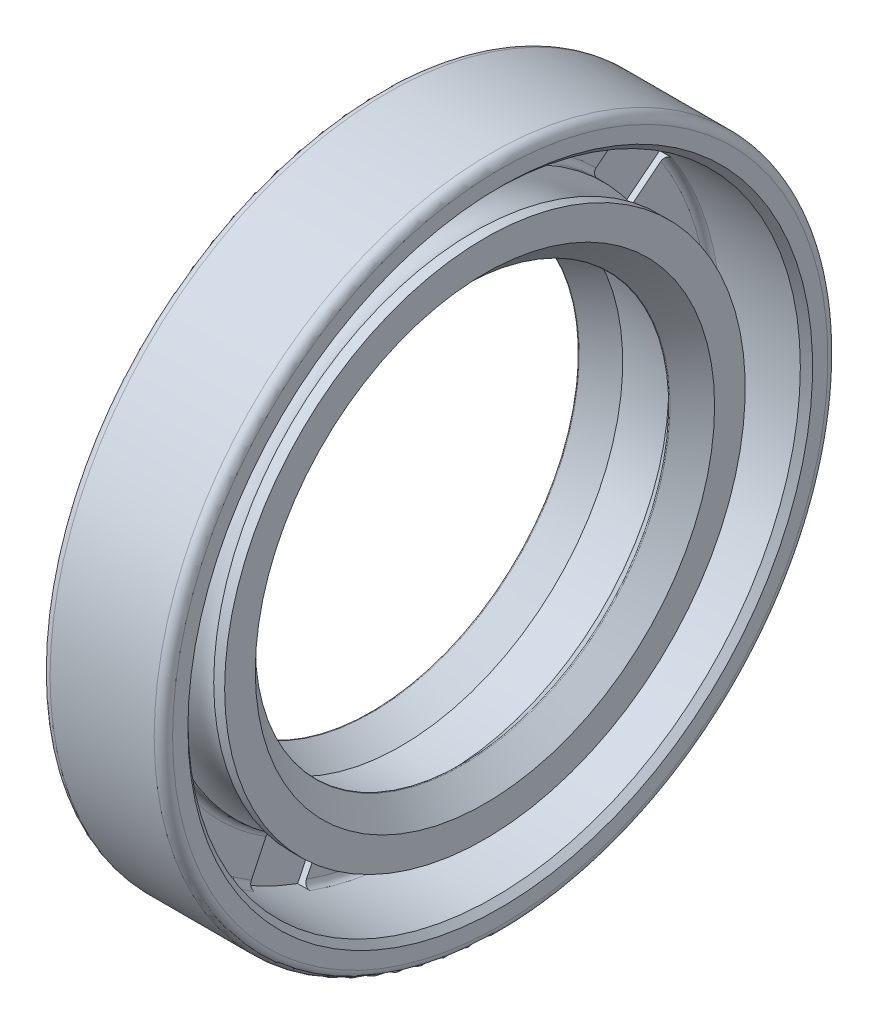
from build123d import *
from build123d.topology import SkipClean

# Parameters (mm, degrees)
CUT_EXTRUDE_1_DEPTH      = 0.1
EXTRUDE_1_DEPTH          = 0.1
CUT_EXTRUDE_2_DEPTH      = 0.3
CUT_EXTRUDE_2_DEPTH_BACK = 0.2


with BuildPart() as part:
    # Эскиз1 → Повернуть1 (revolve)
    with BuildSketch(Plane.XY, mode=Mode.PRIVATE) as revolve_1_sk:
        with BuildLine():
            Line((3.8, 10), (4, 10.2))
            Line((4, 10.2), (4, 10.7))
            ThreePointArc((4, 10.7), (3.912132034, 10.912132034), (3.7, 11))
            Line((3.7, 11), (0.3, 11))
            ThreePointArc((0.3, 11), (0.087867966, 10.912132034), (0, 10.7))
            Line((0, 10.7), (0, 7.5))
            Line((0, 7.5), (0.1, 7.5))
            Line((0.1, 7.5), (0.1, 7.4))
            Line((0.1, 7.4), (-0.226285117, 6.806886442))
            ThreePointArc((-0.226285117, 6.806886442), (-0.221483169, 6.771486649), (-0.186217991, 6.765779527))
            Line((-0.186217991, 6.765779527), (0.75, 7.25))
            Line((0.75, 7.25), (2.25, 7.25))
            Line((2.25, 7.25), (2.728786797, 6.771213203))
            ThreePointArc((2.728786797, 6.771213203), (2.75, 6.762426407), (2.771213203, 6.771213203))
            Line((2.771213203, 6.771213203), (3.5, 7.5))
            Line((3.5, 7.5), (3.5, 8.5))
            Line((3.5, 8.5), (3.143028555, 8.5))
            ThreePointArc((3.143028555, 8.5), (2.25, 7.95), (1.356971445, 8.5))
            Line((1.356971445, 8.5), (1.2, 8.5))
            ThreePointArc((1.2, 8.5), (1.058578644, 8.558578644), (1, 8.7))
            Line((1, 8.7), (1, 9.8))
            ThreePointArc((1, 9.8), (1.058578644, 9.941421356), (1.2, 10))
            Line((1.2, 10), (3.8, 10))
        make_face()
    revolve(revolve_1_sk.sketch.rotate(Axis((0, 0, 0), (1, 0, 0)), 90), axis=Axis((0, 0, 0), (1, 0, 0)))

    # Эскиз2 → Вырез-Вытянуть1 (cut)
    with BuildSketch(Plane.ZY):
        with BuildLine():
            Line((-1, 10.351811436), (-1, 8.851811436))
            ThreePointArc((-1, 8.851811436), (-1.344740951, 7.79988362), (-2.245223812, 7.156044301))
            ThreePointArc((-2.245223812, 7.156044301), (0, 7.5), (2.245223812, 7.156044301))
            ThreePointArc((2.245223812, 7.156044301), (1.344740951, 7.79988362), (1, 8.851811436))
            Line((1, 8.851811436), (1, 10.351811436))
            ThreePointArc((1, 10.351811436), (0, 10.4), (-1, 10.351811436))
        make_face()
        with BuildLine():
            Line((7.469882279, 7.236080343), (6.297135055, 6.300845641))
            ThreePointArc((6.297135055, 6.300845641), (5.259762305, 5.914508704), (4.194946575, 6.217107304))
            ThreePointArc((4.194946575, 6.217107304), (5.863736119, 4.676173514), (6.994694874, 2.706333982))
            ThreePointArc((6.994694874, 2.706333982), (6.936626843, 3.811787082), (7.544114659, 4.737182676))
            Line((7.544114659, 4.737182676), (8.716861883, 5.672417378))
            ThreePointArc((8.716861883, 5.672417378), (8.131047418, 6.484293939), (7.469882279, 7.236080343))
        make_face()
        with BuildLine():
            Line((10.314790844, -1.328566837), (8.852398976, -0.994785436))
            ThreePointArc((8.852398976, -0.994785436), (7.903557265, -0.424611901), (7.476236629, 0.596561702))
            ThreePointArc((7.476236629, 0.596561702), (7.311959341, -1.668907005), (6.47701803, -3.781301024))
            ThreePointArc((6.47701803, -3.781301024), (7.305091241, -3.046662875), (8.407357108, -2.94464126))
            Line((8.407357108, -2.94464126), (9.869748976, -3.278422661))
            ThreePointArc((9.869748976, -3.278422661), (10.139250287, -2.314217713), (10.314790844, -1.328566837))
        make_face()
        with BuildLine():
            Line((5.39245152, -8.892776091), (4.741625912, -7.541322789))
            ThreePointArc((4.741625912, -7.541322789), (4.595812402, -6.443991083), (5.127768014, -5.47320703))
            ThreePointArc((5.127768014, -5.47320703), (3.254128043, -6.757266509), (1.082014503, -7.421539235))
            ThreePointArc((1.082014503, -7.421539235), (2.172672938, -7.610913547), (2.939688176, -8.409090267))
            Line((2.939688176, -8.409090267), (3.590513784, -9.760543569))
            ThreePointArc((3.590513784, -9.760543569), (4.512390887, -9.370076226), (5.39245152, -8.892776091))
        make_face()
        with BuildLine():
            Line((-3.590513784, -9.760543569), (-2.939688176, -8.409090267))
            ThreePointArc((-2.939688176, -8.409090267), (-2.172672938, -7.610913547), (-1.082014503, -7.421539235))
            ThreePointArc((-1.082014503, -7.421539235), (-3.254128043, -6.757266509), (-5.127768014, -5.47320703))
            ThreePointArc((-5.127768014, -5.47320703), (-4.595812402, -6.443991083), (-4.741625912, -7.541322789))
            Line((-4.741625912, -7.541322789), (-5.39245152, -8.892776091))
            ThreePointArc((-5.39245152, -8.892776091), (-4.512390887, -9.370076226), (-3.590513784, -9.760543569))
        make_face()
        with BuildLine():
            Line((-9.869748976, -3.278422661), (-8.407357108, -2.94464126))
            ThreePointArc((-8.407357108, -2.94464126), (-7.305091241, -3.046662875), (-6.47701803, -3.781301024))
            ThreePointArc((-6.47701803, -3.781301024), (-7.311959341, -1.668907005), (-7.476236629, 0.596561702))
            ThreePointArc((-7.476236629, 0.596561702), (-7.903557265, -0.424611901), (-8.852398976, -0.994785436))
            Line((-8.852398976, -0.994785436), (-10.314790844, -1.328566837))
            ThreePointArc((-10.314790844, -1.328566837), (-10.139250287, -2.314217713), (-9.869748976, -3.278422661))
        make_face()
        with BuildLine():
            Line((-8.716861883, 5.672417378), (-7.544114659, 4.737182676))
            ThreePointArc((-7.544114659, 4.737182676), (-6.936626843, 3.811787082), (-6.994694874, 2.706333982))
            ThreePointArc((-6.994694874, 2.706333982), (-5.863736119, 4.676173514), (-4.194946575, 6.217107304))
            ThreePointArc((-4.194946575, 6.217107304), (-5.259762305, 5.914508704), (-6.297135055, 6.300845641))
            Line((-6.297135055, 6.300845641), (-7.469882279, 7.236080343))
            ThreePointArc((-7.469882279, 7.236080343), (-8.131047418, 6.484293939), (-8.716861883, 5.672417378))
        make_face()
    extrude(amount=-CUT_EXTRUDE_1_DEPTH, mode=Mode.SUBTRACT)

    # Эскиз3 → Бобышка-Вытянуть1 (add)
    with BuildSketch(Plane.ZY):
        with BuildLine():
            Line((9.588913533, 1.33928681), (9.468080199, 1.317672227))
            Line((9.468080199, 1.317672227), (9.386569783, 1.76975556))
            Line((9.386569783, 1.76975556), (9.029278116, 1.77053681))
            add(Edge.make_bspline(
                [(9.029278116, 1.77053681), (9.035465049, 1.757775142), (9.04742158, 1.733112633), (9.061601236, 1.695833664), (9.073210139, 1.660384245), (9.078009986, 1.63682296), (9.080319783, 1.625484727)],
                knots=[0, 0, 0, 0, 1.102671341, 2.130962978, 3.100576271, 4, 4, 4, 4], degree=3))
            add(Edge.make_bspline(
                [(9.080319783, 1.625484727), (9.082501781, 1.611277835), (9.086782503, 1.583406247), (9.088462989, 1.541710229), (9.086595342, 1.50120977), (9.080140882, 1.461992911), (9.070367346, 1.423943575), (9.056197187, 1.387243637), (9.037669999, 1.352026263), (9.016054421, 1.318019494), (8.990847303, 1.286399108), (8.962854268, 1.25761246), (8.932291016, 1.231810596), (8.898614543, 1.209773507), (8.86266967, 1.190269117), (8.823778149, 1.174599529), (8.782526714, 1.161196232), (8.753658084, 1.155485034), (8.738913533, 1.15256806)],
                knots=[0, 0, 0, 0, 1.054632134, 2.069014926, 3.058236692, 4.026435499, 4.98181551, 5.938194216, 6.907420423, 7.899266887, 8.892668482, 9.870739776, 10.843480261, 11.822796767, 12.820828869, 13.84110145, 14.897350115, 16, 16, 16, 16], degree=3))
            add(Edge.make_bspline(
                [(8.738913533, 1.15256806), (8.718301703, 1.149499747), (8.677659031, 1.143449608), (8.616404687, 1.144008967), (8.556545655, 1.152050985), (8.508178047, 1.165290204), (8.470735254, 1.178870217), (8.444154528, 1.191425999), (8.418474695, 1.204669458), (8.394558088, 1.220347426), (8.37152675, 1.23690558), (8.349769257, 1.255196589), (8.329609308, 1.275323468), (8.310400181, 1.296613929), (8.293177936, 1.319672847), (8.276698312, 1.343554884), (8.262672315, 1.369251451), (8.249373401, 1.395746425), (8.238373521, 1.423834635), (8.22829654, 1.452936979), (8.220331805, 1.483550735), (8.216074336, 1.504457302), (8.213913533, 1.51506806)],
                knots=[0, 0, 0, 0, 1.746782277, 3.444327802, 5.120713648, 6.803167765, 7.64223887, 8.46046003, 9.268727784, 10.06498721, 10.857739235, 11.648782055, 12.44730472, 13.247155712, 14.052957073, 14.861224827, 15.679964794, 16.5075709, 17.347716724, 18.209383447, 19.091204212, 20, 20, 20, 20], degree=3))
            add(Edge.make_bspline(
                [(8.213913533, 1.51506806), (8.211860736, 1.527713333), (8.207814692, 1.55263705), (8.205793798, 1.589973093), (8.207206721, 1.626283926), (8.211184773, 1.661631073), (8.218837253, 1.695999064), (8.229828493, 1.729367785), (8.24395701, 1.761796776), (8.261138698, 1.792997667), (8.281015382, 1.822460746), (8.30338295, 1.849779748), (8.327776982, 1.874819928), (8.354660779, 1.89733801), (8.383492712, 1.917712939), (8.41476775, 1.935451835), (8.448122544, 1.950923612), (8.471562549, 1.959100239), (8.483444783, 1.963245143)],
                knots=[0, 0, 0, 0, 1.070277629, 2.109507287, 3.118742823, 4.105157841, 5.078705733, 6.056193492, 7.037551653, 8.031278571, 9.029472413, 10.004074294, 10.978973248, 11.947043653, 12.931428349, 13.925923206, 14.948606654, 16, 16, 16, 16], degree=3))
            Line((8.483444783, 1.963245143), (8.506882283, 1.83303681))
            add(Edge.make_bspline(
                [(8.506882283, 1.83303681), (8.495664343, 1.828312816), (8.474049287, 1.819210486), (8.44436308, 1.802356173), (8.418329605, 1.783766395), (8.396397922, 1.762563604), (8.37795042, 1.739236954), (8.362186693, 1.713738496), (8.349096987, 1.685708453), (8.339194806, 1.655511971), (8.332070708, 1.624137755), (8.328625933, 1.592244369), (8.329126299, 1.560235375), (8.332175156, 1.539177467), (8.333705199, 1.528609727)],
                knots=[0, 0, 0, 0, 1.145991483, 2.208130174, 3.209320006, 4.152151774, 5.071818133, 6.004664262, 6.970625265, 7.979303532, 8.993273262, 9.996732158, 10.994676309, 12, 12, 12, 12], degree=3))
            add(Edge.make_bspline(
                [(8.333705199, 1.528609727), (8.335839735, 1.518399078), (8.340037362, 1.498319536), (8.349901331, 1.469362208), (8.362302411, 1.441959603), (8.377789535, 1.416340658), (8.396017482, 1.392409644), (8.416814348, 1.369919107), (8.440755295, 1.349407874), (8.466871381, 1.330418787), (8.494966161, 1.313963304), (8.524309484, 1.30022419), (8.554732046, 1.289874382), (8.586063175, 1.282109357), (8.618491511, 1.278135279), (8.651755457, 1.276877334), (8.686054737, 1.278212844), (8.708992702, 1.281925626), (8.720684366, 1.28381806)],
                knots=[0, 0, 0, 0, 0.981009174, 1.929183594, 2.872417366, 3.806977866, 4.740001525, 5.699616796, 6.684157724, 7.702294877, 8.734980607, 9.743831539, 10.746310718, 11.754930054, 12.776405264, 13.814795504, 14.886183815, 16, 16, 16, 16], degree=3))
            add(Edge.make_bspline(
                [(8.720684366, 1.28381806), (8.731055122, 1.285994385), (8.751398612, 1.290263511), (8.780721187, 1.299415065), (8.808072282, 1.310882369), (8.833568977, 1.324397299), (8.856900782, 1.340471863), (8.878392584, 1.358697855), (8.897661044, 1.379483473), (8.91511876, 1.402073827), (8.930280188, 1.426401237), (8.942244992, 1.452470277), (8.951592086, 1.47961082), (8.958586316, 1.507987621), (8.96206941, 1.537714124), (8.962734891, 1.568556211), (8.961031485, 1.600639017), (8.957602986, 1.622209322), (8.955840616, 1.633297227)],
                knots=[0, 0, 0, 0, 1.071476955, 2.101831487, 3.101497072, 4.067906914, 5.015341607, 5.962043589, 6.91252516, 7.876738478, 8.846612665, 9.8051719, 10.77154185, 11.746965016, 12.755499628, 13.791972177, 14.864995145, 16, 16, 16, 16], degree=3))
            add(Edge.make_bspline(
                [(8.955840616, 1.633297227), (8.953890867, 1.642877789), (8.949885863, 1.66255735), (8.941105073, 1.692271622), (8.930054115, 1.723090319), (8.916893416, 1.755094434), (8.900747926, 1.787965728), (8.882482686, 1.822084346), (8.862054192, 1.857450334), (8.846914154, 1.880929259), (8.839173949, 1.892932643)],
                knots=[0, 0, 0, 0, 0.818829657, 1.681968923, 2.59290151, 3.561306049, 4.579422007, 5.659649051, 6.803517188, 8, 8, 8, 8], degree=3))
            Line((8.839173949, 1.892932643), (9.489955199, 1.888765977))
            Line((9.489955199, 1.888765977), (9.588913533, 1.33928681))
        make_face()
        Polygon((4.381995522, 8.674018158), (4.405693438, 8.663080658), (4.021318438, 7.845632741), (4.163505938, 7.778705658), (4.110641355, 7.666205658), (3.968453855, 7.733132741), (3.840068438, 7.460476491), (3.722880938, 7.515424408), (3.851266355, 7.788080658), (3.290589272, 8.051882741), align=None)
        Polygon((3.904130938, 7.900580658), (4.134078855, 8.389643158), (3.558818438, 8.063080658), align=None, mode=Mode.SUBTRACT)
        with BuildLine():
            Line((-3.829708602, 8.452844517), (-3.944552352, 8.405188267))
            add(Edge.make_bspline(
                [(-3.944552352, 8.405188267), (-3.949859452, 8.41994751), (-3.960313259, 8.449019941), (-3.971057457, 8.493358081), (-3.978110879, 8.536983544), (-3.980294709, 8.580085731), (-3.978938574, 8.622571089), (-3.972892066, 8.664576179), (-3.962237646, 8.705817947), (-3.948162825, 8.746304697), (-3.929896663, 8.784799666), (-3.908766046, 8.821120294), (-3.884292716, 8.854521186), (-3.856455161, 8.884809492), (-3.825811178, 8.912480959), (-3.791738267, 8.936895149), (-3.754655806, 8.958758112), (-3.728101027, 8.970549437), (-3.714604436, 8.976542433)],
                knots=[0, 0, 0, 0, 1.096521486, 2.159903834, 3.186245968, 4.183651723, 5.17415673, 6.155760999, 7.145502496, 8.149981878, 9.149677297, 10.121389001, 11.085767646, 12.039997892, 12.994653141, 13.968847404, 14.967657124, 16, 16, 16, 16], degree=3))
            add(Edge.make_bspline(
                [(-3.714604436, 8.976542433), (-3.700967671, 8.981800704), (-3.674298183, 8.992084331), (-3.633728967, 9.003442013), (-3.5936637, 9.010232709), (-3.55421364, 9.012941536), (-3.515385206, 9.011273051), (-3.477090376, 9.005937321), (-3.439394044, 8.995875642), (-3.402733974, 8.9817443), (-3.367543252, 8.964798788), (-3.33477103, 8.944880717), (-3.304782781, 8.922461629), (-3.277332771, 8.897555308), (-3.253032619, 8.869819767), (-3.230792357, 8.839993144), (-3.211790224, 8.807307801), (-3.201379274, 8.784107352), (-3.196114852, 8.772375767)],
                knots=[0, 0, 0, 0, 1.126668478, 2.203431106, 3.242301841, 4.255315755, 5.246847215, 6.23423487, 7.231174724, 8.248139917, 9.260069506, 10.239345753, 11.200610572, 12.143519972, 13.091902427, 14.039812275, 15.008807544, 16, 16, 16, 16], degree=3))
            add(Edge.make_bspline(
                [(-3.196114852, 8.772375767), (-3.18963113, 8.755424988), (-3.176769082, 8.721798977), (-3.166249159, 8.668819192), (-3.161492723, 8.615155709), (-3.163984029, 8.569420349), (-3.169204722, 8.531104079), (-3.175335459, 8.498976953), (-3.183384434, 8.463704251), (-3.193702689, 8.425272747), (-3.205898583, 8.383665582), (-3.220426765, 8.338872854), (-3.236311812, 8.290711742), (-3.248442574, 8.257843253), (-3.254708602, 8.24086535)],
                knots=[0, 0, 0, 0, 1.188437879, 2.357556985, 3.528739948, 4.714365017, 5.352092814, 6.064537005, 6.858720112, 7.724625659, 8.674082858, 9.70222094, 10.813104245, 12, 12, 12, 12], degree=3))
            Line((-3.254708602, 8.24086535), (-3.418510686, 7.79555285))
            Line((-3.418510686, 7.79555285), (-2.865906519, 8.025500767))
            Line((-2.865906519, 8.025500767), (-2.817729436, 7.909875767))
            Line((-2.817729436, 7.909875767), (-3.630750269, 7.571594517))
            Line((-3.630750269, 7.571594517), (-3.379187769, 8.255969517))
            add(Edge.make_bspline(
                [(-3.379187769, 8.255969517), (-3.373044883, 8.272525513), (-3.361210096, 8.304422034), (-3.345245929, 8.350701861), (-3.330789427, 8.393165163), (-3.318421622, 8.43191544), (-3.308581228, 8.467153469), (-3.30049242, 8.49866531), (-3.29398151, 8.52646694), (-3.28882884, 8.5585649), (-3.28607861, 8.595878122), (-3.288390751, 8.639198683), (-3.296247868, 8.681394616), (-3.306220137, 8.707998268), (-3.311219019, 8.7213341)],
                knots=[0, 0, 0, 0, 1.31832802, 2.539869931, 3.654741466, 4.667269092, 5.576164967, 6.385658026, 7.09632402, 7.706819853, 8.811282941, 9.882190626, 10.938388291, 12, 12, 12, 12], degree=3))
            add(Edge.make_bspline(
                [(-3.311219019, 8.7213341), (-3.314881885, 8.729484973), (-3.322153229, 8.745665696), (-3.335706648, 8.768336319), (-3.351486167, 8.788986849), (-3.369019018, 8.807921236), (-3.388570976, 8.82488006), (-3.410248629, 8.839770105), (-3.433655224, 8.853201424), (-3.459022006, 8.864049005), (-3.485112496, 8.873327484), (-3.511833881, 8.87963576), (-3.538645531, 8.882846255), (-3.565573225, 8.884082899), (-3.592563893, 8.882241098), (-3.619637857, 8.877371906), (-3.646862316, 8.870143325), (-3.664659656, 8.863339242), (-3.673719019, 8.859875767)],
                knots=[0, 0, 0, 0, 0.993378952, 1.972008145, 2.929839696, 3.879460273, 4.837729712, 5.801963692, 6.800770985, 7.834077465, 8.866165237, 9.877909366, 10.880303721, 11.865909819, 12.872341706, 13.881918122, 14.921834737, 16, 16, 16, 16], degree=3))
            add(Edge.make_bspline(
                [(-3.673719019, 8.859875767), (-3.6830189, 8.855818349), (-3.701278625, 8.847851866), (-3.726584708, 8.832725104), (-3.749907143, 8.816161223), (-3.770922481, 8.797378237), (-3.789999254, 8.776977196), (-3.806446354, 8.754276853), (-3.820818782, 8.729947355), (-3.833107099, 8.703938749), (-3.842713877, 8.676359875), (-3.849507899, 8.647559687), (-3.853394247, 8.617721228), (-3.854418722, 8.586764066), (-3.852433838, 8.5547253), (-3.848090445, 8.5215136), (-3.84045012, 8.487310313), (-3.833346201, 8.464516308), (-3.829708602, 8.452844517)],
                knots=[0, 0, 0, 0, 1.002791797, 1.968918082, 2.910264302, 3.828773152, 4.752445691, 5.667898733, 6.595713322, 7.544549858, 8.5086514, 9.479270434, 10.466648568, 11.480519657, 12.538453784, 13.638754709, 14.79091189, 16, 16, 16, 16], degree=3))
        make_face()
        with BuildLine():
            Line((-4.803383084, 7.936228802), (-4.911195584, 7.875551719))
            add(Edge.make_bspline(
                [(-4.911195584, 7.875551719), (-4.918117154, 7.889507673), (-4.931768312, 7.917032487), (-4.947788447, 7.95939507), (-4.959841908, 8.001703843), (-4.966934077, 8.04398293), (-4.970589336, 8.086246753), (-4.969434347, 8.128402835), (-4.964154857, 8.17051965), (-4.954817842, 8.212108652), (-4.941740388, 8.252566881), (-4.924578976, 8.290709227), (-4.904563186, 8.326736529), (-4.88072613, 8.36010327), (-4.853530249, 8.391129345), (-4.822513208, 8.419125361), (-4.788557738, 8.445330195), (-4.763704764, 8.4601744), (-4.751039334, 8.467739219)],
                knots=[0, 0, 0, 0, 1.093816138, 2.157293325, 3.176725589, 4.179274344, 5.164272884, 6.152475292, 7.13577344, 8.141821374, 9.142680977, 10.117260979, 11.075622659, 12.033343872, 12.992520074, 13.967996364, 14.964461964, 16, 16, 16, 16], degree=3))
            add(Edge.make_bspline(
                [(-4.751039334, 8.467739219), (-4.738223847, 8.474583159), (-4.713101342, 8.487999497), (-4.674138623, 8.503549845), (-4.635379641, 8.515182713), (-4.596641067, 8.522664782), (-4.557943364, 8.525348534), (-4.519336861, 8.524528221), (-4.480967872, 8.518816152), (-4.443017213, 8.509525257), (-4.406444543, 8.496459694), (-4.371603657, 8.481000913), (-4.339344462, 8.462244295), (-4.309265186, 8.440994952), (-4.281786745, 8.416444525), (-4.256420367, 8.38938955), (-4.233645949, 8.359292917), (-4.220635448, 8.337571175), (-4.214060168, 8.326593385)],
                knots=[0, 0, 0, 0, 1.123995911, 2.20339595, 3.240965662, 4.253156185, 5.250447687, 6.2386417, 7.236499041, 8.24699283, 9.25864785, 10.239134739, 11.193505465, 12.142633332, 13.085196562, 14.040867601, 15.009888581, 16, 16, 16, 16], degree=3))
            add(Edge.make_bspline(
                [(-4.214060168, 8.326593385), (-4.205738272, 8.310550627), (-4.189254274, 8.27877316), (-4.172018278, 8.227839312), (-4.161637067, 8.175218396), (-4.158353148, 8.129678553), (-4.159185652, 8.091145511), (-4.161371643, 8.058660686), (-4.164977605, 8.022858865), (-4.170569518, 7.983615085), (-4.177937647, 7.94100852), (-4.186799568, 7.894994973), (-4.197216766, 7.845573592), (-4.205219831, 7.811646345), (-4.209372668, 7.794041302)],
                knots=[0, 0, 0, 0, 1.188925002, 2.355020631, 3.526652616, 4.713156068, 5.353552139, 6.063922859, 6.85690597, 7.722805645, 8.673945646, 9.704338504, 10.80876811, 12, 12, 12, 12], degree=3))
            Line((-4.209372668, 7.794041302), (-4.319008084, 7.334145469))
            Line((-4.319008084, 7.334145469), (-3.799476834, 7.627114219))
            Line((-3.799476834, 7.627114219), (-3.738278918, 7.518520469))
            Line((-3.738278918, 7.518520469), (-4.502601834, 7.087791302))
            Line((-4.502601834, 7.087791302), (-4.334372668, 7.794301719))
            add(Edge.make_bspline(
                [(-4.334372668, 7.794301719), (-4.330215646, 7.811471535), (-4.322232146, 7.844445925), (-4.311971793, 7.892180698), (-4.302747737, 7.935892728), (-4.295096839, 7.975712801), (-4.289308904, 8.011761235), (-4.285254523, 8.043913134), (-4.282079136, 8.072191101), (-4.280716524, 8.104460545), (-4.28240452, 8.141638725), (-4.289614933, 8.184235249), (-4.302580351, 8.224969602), (-4.315442542, 8.250185337), (-4.321872668, 8.262791302)],
                knots=[0, 0, 0, 0, 1.323703953, 2.542154804, 3.658395355, 4.671322923, 5.580296802, 6.393557515, 7.099691824, 7.711680269, 8.812193497, 9.881567138, 10.940943348, 12, 12, 12, 12], degree=3))
            add(Edge.make_bspline(
                [(-4.321872668, 8.262791302), (-4.326522974, 8.270422686), (-4.335718589, 8.285513146), (-4.351549452, 8.30656144), (-4.369701747, 8.324917234), (-4.389174168, 8.341658667), (-4.410456775, 8.356210479), (-4.433697038, 8.36844416), (-4.458440493, 8.37901633), (-4.484783544, 8.386821935), (-4.511763803, 8.392642911), (-4.538885724, 8.395735913), (-4.565847534, 8.396386855), (-4.592531439, 8.393908443), (-4.619011912, 8.389050423), (-4.645176218, 8.380999487), (-4.671308644, 8.370705063), (-4.688095639, 8.361826797), (-4.696612251, 8.357322552)],
                knots=[0, 0, 0, 0, 0.997680993, 1.972835486, 2.932499176, 3.874524755, 4.837023499, 5.804050757, 6.803190383, 7.83653798, 8.866926321, 9.881694852, 10.880270099, 11.87280533, 12.868978396, 13.880965465, 14.924941931, 16, 16, 16, 16], degree=3))
            add(Edge.make_bspline(
                [(-4.696612251, 8.357322552), (-4.705291946, 8.352074401), (-4.722308708, 8.341785267), (-4.74596039, 8.32432308), (-4.766876384, 8.304903835), (-4.78543912, 8.283899887), (-4.80206103, 8.261513291), (-4.815802603, 8.237224609), (-4.827041084, 8.21133647), (-4.83622046, 8.184213364), (-4.842399694, 8.155738954), (-4.845884304, 8.126433239), (-4.846021176, 8.09641285), (-4.843355028, 8.06565491), (-4.837852631, 8.034207246), (-4.829447443, 8.001972183), (-4.81792739, 7.969096019), (-4.808310524, 7.947363829), (-4.803383084, 7.936228802)],
                knots=[0, 0, 0, 0, 1.006622235, 1.973508445, 2.912614938, 3.834361958, 4.753042397, 5.675473967, 6.597704251, 7.551483334, 8.513287118, 9.48492351, 10.475969956, 11.487889852, 12.546190879, 13.641423437, 14.791524732, 16, 16, 16, 16], degree=3))
        make_face()
        Polygon((-9.249183581, 2.983381523), (-9.241631497, 3.008902356), (-8.374183581, 2.754996106), (-8.330173164, 2.905516939), (-8.210902331, 2.870621106), (-8.254912747, 2.720100273), (-7.965329414, 2.635464856), (-8.001787747, 2.510985689), (-8.291371081, 2.595621106), (-8.465589831, 2.000569023), align=None)
        Polygon((-8.410641914, 2.630516939), (-8.929391914, 2.782339856), (-8.517933581, 2.264110689), align=None, mode=Mode.SUBTRACT)
        Polygon((-9.567350313, 1.426155123), (-9.525683646, 1.67563429), (-8.256673229, 1.463394707), (-8.277766979, 1.33735304), (-9.422558646, 1.52875929), (-9.455891979, 1.32954054), align=None)
        with BuildLine():
            Line((-7.955194418, -5.086215433), (-7.831756918, -5.121892516))
            add(Edge.make_bspline(
                [(-7.831756918, -5.121892516), (-7.837446833, -5.143831138), (-7.848690993, -5.187185273), (-7.855500665, -5.253486488), (-7.85558739, -5.319203402), (-7.847019287, -5.38414647), (-7.831145678, -5.447976076), (-7.807486348, -5.510001169), (-7.776332098, -5.570203526), (-7.750409525, -5.607746568), (-7.737225668, -5.626840433)],
                knots=[0, 0, 0, 0, 1.019327099, 2.014349226, 2.991613848, 3.972966547, 4.956123806, 5.947114247, 6.955931101, 8, 8, 8, 8], degree=3))
            add(Edge.make_bspline(
                [(-7.737225668, -5.626840433), (-7.729470877, -5.637028341), (-7.714080658, -5.657247346), (-7.688594965, -5.685298963), (-7.662026251, -5.711673059), (-7.634152862, -5.736275775), (-7.604655484, -5.7587418), (-7.573549653, -5.778966954), (-7.541236127, -5.79764391), (-7.507448731, -5.813827055), (-7.473016201, -5.82824212), (-7.438060092, -5.839859887), (-7.402956978, -5.849394016), (-7.367701413, -5.856305343), (-7.332234979, -5.861192129), (-7.296628539, -5.863123752), (-7.260779789, -5.862981349), (-7.224941898, -5.860018336), (-7.18926825, -5.854856281), (-7.154040055, -5.847259614), (-7.119276836, -5.837403226), (-7.085196761, -5.824859221), (-7.051678529, -5.809859696), (-7.018673536, -5.792732148), (-6.98614299, -5.773183689), (-6.965425757, -5.758324071), (-6.954934001, -5.750798766)],
                knots=[0, 0, 0, 0, 1.042867935, 2.069684096, 3.085034209, 4.09246917, 5.096919868, 6.103361058, 7.114068529, 8.135902488, 9.153934648, 10.153792178, 11.135240504, 12.116000371, 13.079362928, 14.050072394, 15.019156896, 15.998385123, 16.977715533, 17.954411302, 18.932821673, 19.919684331, 20.910796584, 21.923185766, 22.948246268, 24, 24, 24, 24], degree=3))
            add(Edge.make_bspline(
                [(-6.954934001, -5.750798766), (-6.939673542, -5.738931628), (-6.909671843, -5.715601117), (-6.86948275, -5.676210952), (-6.834066093, -5.634427678), (-6.803667362, -5.589926263), (-6.778300513, -5.542786402), (-6.757737017, -5.493013557), (-6.742895377, -5.440430749), (-6.732346761, -5.38600234), (-6.727497437, -5.330589867), (-6.727974297, -5.275380326), (-6.733900275, -5.220893542), (-6.74580991, -5.16727289), (-6.763033125, -5.114356551), (-6.786170226, -5.062470358), (-6.814667001, -5.011285898), (-6.837364295, -4.97882076), (-6.848944418, -4.962257099)],
                knots=[0, 0, 0, 0, 1.042177306, 2.048895713, 3.029226845, 3.992987743, 4.950505247, 5.912307326, 6.891967151, 7.893049795, 8.899125402, 9.887254745, 10.867227904, 11.850072351, 12.845222927, 13.864163587, 14.910299745, 16, 16, 16, 16], degree=3))
            add(Edge.make_bspline(
                [(-6.848944418, -4.962257099), (-6.86264914, -4.944761444), (-6.889649707, -4.910292112), (-6.935785365, -4.864579516), (-6.985678505, -4.825105384), (-7.03938547, -4.791947454), (-7.096659665, -4.764554477), (-7.157863191, -4.744188204), (-7.222556291, -4.729168436), (-7.267271206, -4.724695825), (-7.290090251, -4.722413349)],
                knots=[0, 0, 0, 0, 1.026940933, 2.023243287, 2.994974344, 3.963000453, 4.936197949, 5.92380143, 6.94046832, 8, 8, 8, 8], degree=3))
            Line((-7.290090251, -4.722413349), (-7.288267335, -4.594548766))
            add(Edge.make_bspline(
                [(-7.288267335, -4.594548766), (-7.275322997, -4.595188797), (-7.249460198, -4.596467578), (-7.211007401, -4.600904601), (-7.173083845, -4.607680497), (-7.135816681, -4.616883014), (-7.098926581, -4.628095135), (-7.062525393, -4.641552375), (-7.026813504, -4.657622869), (-6.991553093, -4.675456272), (-6.957328213, -4.695963273), (-6.923554276, -4.717861414), (-6.891397077, -4.742583321), (-6.859905372, -4.768860353), (-6.829769922, -4.797601342), (-6.800583563, -4.828379858), (-6.772356396, -4.861187599), (-6.754729359, -4.884385446), (-6.745819418, -4.896111266)],
                knots=[0, 0, 0, 0, 0.967137768, 1.932342106, 2.886787599, 3.840639156, 4.795722171, 5.76333727, 6.734978614, 7.717275935, 8.710664369, 9.711588309, 10.719741644, 11.735961412, 12.771717985, 13.825793733, 14.901003564, 16, 16, 16, 16], degree=3))
            add(Edge.make_bspline(
                [(-6.745819418, -4.896111266), (-6.737622068, -4.907485196), (-6.721481733, -4.929880119), (-6.699726259, -4.964492857), (-6.679482016, -4.998832695), (-6.661528724, -5.033534012), (-6.645570733, -5.068333711), (-6.632067548, -5.103456994), (-6.620267045, -5.138603521), (-6.610547028, -5.17396324), (-6.603431915, -5.209505437), (-6.597687912, -5.245004987), (-6.594815081, -5.280782217), (-6.593260277, -5.316679286), (-6.594562576, -5.352754552), (-6.597207693, -5.388951675), (-6.602562888, -5.425262345), (-6.607429926, -5.449343748), (-6.609881918, -5.461475849)],
                knots=[0, 0, 0, 0, 1.119687172, 2.204630135, 3.264304773, 4.303290001, 5.324231341, 6.320935703, 7.307700651, 8.285040227, 9.247881537, 10.202119719, 11.155753028, 12.113311184, 13.070643344, 14.037521325, 15.011312124, 16, 16, 16, 16], degree=3))
            add(Edge.make_bspline(
                [(-6.609881918, -5.461475849), (-6.61505313, -5.481645591), (-6.625297055, -5.521600887), (-6.647326866, -5.579134625), (-6.673859398, -5.634160693), (-6.705868736, -5.6863651), (-6.742654107, -5.736023917), (-6.784660599, -5.782825341), (-6.83158574, -5.827063448), (-6.866069354, -5.853686208), (-6.883579835, -5.867205016)],
                knots=[0, 0, 0, 0, 0.998298794, 1.977582301, 2.949888962, 3.92557918, 4.910972013, 5.910868003, 6.939156823, 8, 8, 8, 8], degree=3))
            add(Edge.make_bspline(
                [(-6.883579835, -5.867205016), (-6.90260711, -5.880522208), (-6.940104525, -5.906766654), (-6.99978956, -5.938995289), (-7.060779267, -5.96483269), (-7.123301803, -5.983676517), (-7.187215151, -5.995636263), (-7.252482339, -6.001218292), (-7.319213991, -5.999690904), (-7.386625128, -5.991982264), (-7.453296743, -5.977792492), (-7.517633134, -5.957081125), (-7.579155621, -5.930514675), (-7.637543547, -5.897498304), (-7.692698441, -5.858107789), (-7.744896817, -5.812852791), (-7.794299507, -5.761605364), (-7.823767546, -5.723571187), (-7.838788168, -5.704184183)],
                knots=[0, 0, 0, 0, 1.029318466, 2.028497569, 3.001623271, 3.962579826, 4.918487368, 5.880499847, 6.862396894, 7.873820131, 8.88563162, 9.880328393, 10.866585616, 11.852662489, 12.849324156, 13.867378502, 14.912947644, 16, 16, 16, 16], degree=3))
            add(Edge.make_bspline(
                [(-7.838788168, -5.704184183), (-7.847528344, -5.692043986), (-7.864813346, -5.668034933), (-7.887884492, -5.630723811), (-7.908571917, -5.593085279), (-7.92685174, -5.555013436), (-7.942696538, -5.516474706), (-7.956384036, -5.477590046), (-7.967349016, -5.438180171), (-7.975585364, -5.39839426), (-7.981597052, -5.358491116), (-7.985321858, -5.31875819), (-7.986303444, -5.27926525), (-7.985004005, -5.24013686), (-7.981418486, -5.201151235), (-7.975085878, -5.162473126), (-7.966580651, -5.12400226), (-7.959000372, -5.098846029), (-7.955194418, -5.086215433)],
                knots=[0, 0, 0, 0, 1.09802585, 2.171510039, 3.218307861, 4.25023539, 5.270464994, 6.276259497, 7.275164914, 8.271382908, 9.257457834, 10.236650127, 11.199359623, 12.155889157, 13.109697044, 14.071562317, 15.031758069, 16, 16, 16, 16], degree=3))
        make_face()
        Polygon((-6.606151847, -6.910927968), (-6.694693513, -6.999469634), (-7.193912263, -6.500250884), (-7.105370597, -6.411709218), (-6.902506013, -6.614573801), (-6.081151847, -5.793219634), (-5.988443513, -5.885927968), (-6.80979768, -6.707282134), align=None)
        with BuildLine():
            Line((-1.169989697, -8.306872675), (-1.42832303, -9.575883091))
            Line((-1.42832303, -9.575883091), (-1.691343864, -9.522497675))
            add(Edge.make_bspline(
                [(-1.691343864, -9.522497675), (-1.714191908, -9.517633724), (-1.758333652, -9.508236715), (-1.821788178, -9.493307925), (-1.880004506, -9.477564264), (-1.933153644, -9.461867348), (-1.981155833, -9.445545742), (-2.023992088, -9.428591812), (-2.061819166, -9.411513242), (-2.084567487, -9.398609407), (-2.095250114, -9.392549758)],
                knots=[0, 0, 0, 0, 1.316073782, 2.542615422, 3.671991785, 4.713309756, 5.664454128, 6.527201701, 7.308372948, 8, 8, 8, 8], degree=3))
            add(Edge.make_bspline(
                [(-2.095250114, -9.392549758), (-2.109215924, -9.383846589), (-2.13674683, -9.366689965), (-2.174806909, -9.337086753), (-2.210340837, -9.305758712), (-2.241920718, -9.271061531), (-2.271142777, -9.234570429), (-2.296941758, -9.195431785), (-2.319386386, -9.15368876), (-2.338845173, -9.109831549), (-2.355087431, -9.064084397), (-2.367158541, -9.01670612), (-2.376214951, -8.968274665), (-2.380966219, -8.918436085), (-2.382583584, -8.867456853), (-2.380499285, -8.815233088), (-2.374403095, -8.761837409), (-2.367855536, -8.726109908), (-2.364520947, -8.707914341)],
                knots=[0, 0, 0, 0, 1.001440721, 1.974147616, 2.932470686, 3.882623709, 4.827068905, 5.77711899, 6.73268261, 7.71006084, 8.696460471, 9.684982459, 10.684496014, 11.693871622, 12.730440068, 13.788513163, 14.873717565, 16, 16, 16, 16], degree=3))
            add(Edge.make_bspline(
                [(-2.364520947, -8.707914341), (-2.361039363, -8.692335755), (-2.354165975, -8.661580311), (-2.341149609, -8.616756327), (-2.325727278, -8.573891517), (-2.30810087, -8.532947045), (-2.287885572, -8.494084732), (-2.26585532, -8.456964194), (-2.241212175, -8.421960003), (-2.214505504, -8.388976632), (-2.185990944, -8.35849944), (-2.156367822, -8.330367112), (-2.125765502, -8.304939647), (-2.094132852, -8.282016995), (-2.061191702, -8.262266821), (-2.02732563, -8.245066893), (-1.992462603, -8.230345981), (-1.956293948, -8.218234927), (-1.917977349, -8.208973965), (-1.877094024, -8.202987287), (-1.833436701, -8.199180932), (-1.786979257, -8.19897428), (-1.737606068, -8.201009546), (-1.685381118, -8.206074867), (-1.630283945, -8.213867904), (-1.59287723, -8.221114062), (-1.57363553, -8.224841425)],
                knots=[0, 0, 0, 0, 1.088371306, 2.148676446, 3.180389805, 4.193181729, 5.186003928, 6.165662406, 7.134585217, 8.10253109, 9.05746571, 9.978669573, 10.886655503, 11.768842988, 12.639878021, 13.502910984, 14.357149439, 15.218231309, 16.101212842, 17.041373775, 18.033401539, 19.087142902, 20.206934292, 21.402062111, 22.663642586, 24, 24, 24, 24], degree=3))
            Line((-1.57363553, -8.224841425), (-1.169989697, -8.306872675))
        make_face()
        with BuildLine():
            Line((-1.316083447, -8.401924758), (-1.46269803, -8.372237258))
            add(Edge.make_bspline(
                [(-1.46269803, -8.372237258), (-1.483769623, -8.367952537), (-1.524267511, -8.359717652), (-1.582853168, -8.349757646), (-1.636469865, -8.341248779), (-1.685267789, -8.334935956), (-1.72930111, -8.330652058), (-1.768566788, -8.328532977), (-1.80302522, -8.32817388), (-1.824249742, -8.329991533), (-1.834052197, -8.330831008)],
                knots=[0, 0, 0, 0, 1.376749795, 2.646001101, 3.804730377, 4.852646152, 5.796188728, 6.636659707, 7.370347088, 8, 8, 8, 8], degree=3))
            add(Edge.make_bspline(
                [(-1.834052197, -8.330831008), (-1.846586278, -8.332543214), (-1.871309464, -8.335920502), (-1.90746842, -8.34436765), (-1.942241783, -8.355561906), (-1.975580282, -8.369663147), (-2.007470402, -8.386372746), (-2.037895299, -8.405773084), (-2.066786821, -8.427941804), (-2.094092644, -8.452711285), (-2.119705006, -8.47972834), (-2.142929007, -8.509367236), (-2.163994514, -8.541202707), (-2.183062999, -8.575101185), (-2.199819803, -8.611221555), (-2.213985777, -8.649608172), (-2.2264022, -8.690101103), (-2.232675694, -8.718109502), (-2.235875114, -8.732393508)],
                knots=[0, 0, 0, 0, 0.994048255, 1.96073736, 2.914575821, 3.862586942, 4.802706054, 5.741635643, 6.695669363, 7.661924834, 8.637055123, 9.618610989, 10.617915397, 11.635322442, 12.673368097, 13.744399602, 14.849666172, 16, 16, 16, 16], degree=3))
            add(Edge.make_bspline(
                [(-2.235875114, -8.732393508), (-2.23869098, -8.747465649), (-2.244233133, -8.777130454), (-2.248788185, -8.821524684), (-2.250589812, -8.864866683), (-2.248489481, -8.907052615), (-2.244367588, -8.94820068), (-2.236401481, -8.988153401), (-2.225469972, -9.027089924), (-2.21145127, -9.064719933), (-2.19456482, -9.100755374), (-2.174670137, -9.134671346), (-2.152224695, -9.166582324), (-2.127096168, -9.196339575), (-2.099482556, -9.2241733), (-2.068678069, -9.249305688), (-2.035710762, -9.27309994), (-2.01179845, -9.286525523), (-1.999677197, -9.293331008)],
                knots=[0, 0, 0, 0, 1.121893789, 2.208097738, 3.263536738, 4.2938318, 5.297227782, 6.287888846, 7.271515445, 8.254649389, 9.223887332, 10.180695274, 11.129111861, 12.076080027, 13.028574383, 13.994244375, 14.983273981, 16, 16, 16, 16], degree=3))
            add(Edge.make_bspline(
                [(-1.999677197, -9.293331008), (-1.989584129, -9.298500009), (-1.968093746, -9.30950596), (-1.932421244, -9.324157667), (-1.891765982, -9.338595285), (-1.846075442, -9.353165675), (-1.795367436, -9.367694954), (-1.739601607, -9.381953397), (-1.678797419, -9.395991495), (-1.636499312, -9.404865732), (-1.614520947, -9.409476841)],
                knots=[0, 0, 0, 0, 0.674325156, 1.435787921, 2.291670338, 3.240474577, 4.28811422, 5.429079164, 6.664133204, 8, 8, 8, 8], degree=3))
            Line((-1.614520947, -9.409476841), (-1.524677197, -9.427706008))
            Line((-1.524677197, -9.427706008), (-1.316083447, -8.401924758))
        make_face(mode=Mode.SUBTRACT)
        Polygon((-0.189709649, -9.682930977), (-0.321480483, -9.674597644), (-0.291011733, -9.189441394), (-0.837626316, -9.64204556), (-1.012365899, -9.63110806), (-0.354553399, -9.089962227), (-0.979553399, -8.335274727), (-0.808199233, -8.34595181), (-0.278251316, -8.984493477), (-0.240230483, -8.381628894), (-0.108459649, -8.389962227), align=None)
        with BuildLine():
            Line((0.406362662, -9.675627645), (0.276414746, -9.682919312))
            Line((0.276414746, -9.682919312), (0.227456412, -8.810002645))
            add(Edge.make_bspline(
                [(0.227456412, -8.810002645), (0.22668895, -8.79385913), (0.225212256, -8.762796959), (0.224254789, -8.71808383), (0.223926969, -8.677169363), (0.225781184, -8.64010529), (0.227725683, -8.606690513), (0.231722964, -8.577066482), (0.236508275, -8.551198963), (0.244354419, -8.522034589), (0.258256119, -8.489623863), (0.279927748, -8.45441813), (0.307245574, -8.422904582), (0.339884707, -8.395638505), (0.37730948, -8.372860193), (0.419157418, -8.355542545), (0.465297418, -8.344303848), (0.497534723, -8.341432639), (0.514175162, -8.339950562)],
                knots=[0, 0, 0, 0, 1.221627565, 2.350566367, 3.380772656, 4.313383003, 5.155370053, 5.909865628, 6.571341702, 7.142823414, 8.189696496, 9.223990591, 10.256722385, 11.327928767, 12.426284724, 13.555928892, 14.738405172, 16, 16, 16, 16], degree=3))
            add(Edge.make_bspline(
                [(0.514175162, -8.339950562), (0.527200299, -8.339613241), (0.553299106, -8.338937342), (0.59248442, -8.342459916), (0.631539048, -8.349824064), (0.67099799, -8.361206712), (0.711615948, -8.377445897), (0.754242392, -8.399002092), (0.798976892, -8.426545312), (0.828799938, -8.447835914), (0.844383496, -8.458960979)],
                knots=[0, 0, 0, 0, 0.871217199, 1.745680749, 2.626218103, 3.526924134, 4.488965712, 5.548712224, 6.719118598, 8, 8, 8, 8], degree=3))
            Line((0.844383496, -8.458960979), (0.781623079, -8.565731812))
            add(Edge.make_bspline(
                [(0.781623079, -8.565731812), (0.764943587, -8.555534979), (0.733443287, -8.5362776), (0.687771485, -8.510968902), (0.646855952, -8.490242262), (0.620412329, -8.479714241), (0.608185579, -8.474846395)],
                knots=[0, 0, 0, 0, 1.196153765, 2.259013881, 3.19501945, 4, 4, 4, 4], degree=3))
            add(Edge.make_bspline(
                [(0.608185579, -8.474846395), (0.60076966, -8.472243633), (0.586309786, -8.467168656), (0.56417494, -8.462585101), (0.542447732, -8.460024801), (0.528070191, -8.460358251), (0.520945996, -8.460523479)],
                knots=[0, 0, 0, 0, 1.058321997, 2.063561049, 3.040477808, 4, 4, 4, 4], degree=3))
            add(Edge.make_bspline(
                [(0.520945996, -8.460523479), (0.51185196, -8.461299707), (0.493948147, -8.462827901), (0.46823615, -8.471267861), (0.443817026, -8.48282069), (0.421499956, -8.498843188), (0.401727946, -8.518051901), (0.385150518, -8.540083823), (0.372226978, -8.564808555), (0.364311789, -8.587580682), (0.359847454, -8.608409654), (0.357394995, -8.627395473), (0.355599379, -8.649556494), (0.354722927, -8.674838947), (0.354032576, -8.703318262), (0.354821577, -8.735007515), (0.355725007, -8.769999549), (0.356998384, -8.794379801), (0.357664746, -8.807138062)],
                knots=[0, 0, 0, 0, 1.003531138, 1.975694145, 2.964917636, 3.974460178, 4.990113944, 5.995470515, 7.001966301, 8.055719128, 8.643538494, 9.3490283, 10.16564352, 11.095190836, 12.139022374, 13.307307915, 14.5909059, 16, 16, 16, 16], degree=3))
            Line((0.357664746, -8.807138062), (0.406362662, -9.675627645))
        make_face()
        Polygon((2.135257925, -9.443100403), (1.987080841, -9.469142069), (1.596195425, -9.027475403), (1.377185008, -9.576694153), (1.230570425, -9.602735819), (1.499841258, -8.920964986), (0.981872508, -8.338152486), (1.130049591, -8.311850403), (1.553487091, -8.786069153), (1.790987091, -8.195444153), (1.939164175, -8.169142069), (1.650101675, -8.894402486), align=None)
    extrude(amount=EXTRUDE_1_DEPTH)

    # Эскиз4 → Вырез-Вытянуть2 (cut, two sides)
    with SkipClean():  # the faces are left unmerged after this step: merging them gives an invalid solid
        with BuildSketch(Plane(origin=(1, 0, 0), x_dir=(0, 0, -1), z_dir=(1, 0, 0))) as cut_extrude_2_sk:
            with BuildLine():
                Line((-1, 9.949874371), (-1, 8.440971508))
                ThreePointArc((-1, 8.440971508), (0, 8.5), (1, 8.440971508))
                Line((1, 8.440971508), (1, 9.949874371))
                ThreePointArc((1, 9.949874371), (0, 10), (-1, 9.949874371))
            make_face()
            with BuildLine():
                Line((7.155635228, 6.985476683), (5.975927466, 6.044691136))
                ThreePointArc((5.975927466, 6.044691136), (6.645567601, 5.299663316), (7.222907069, 4.481028171))
                Line((7.222907069, 4.481028171), (8.402614832, 5.421813718))
                ThreePointArc((8.402614832, 5.421813718), (7.818314825, 6.234898019), (7.155635228, 6.985476683))
            make_face()
            with BuildLine():
                Line((9.922931181, -1.239127426), (8.451859663, -0.903364951))
                ThreePointArc((8.451859663, -0.903364951), (8.286887254, -1.891427939), (8.006817795, -2.853220776))
                Line((8.006817795, -2.853220776), (9.477889313, -3.18898325))
                ThreePointArc((9.477889313, -3.18898325), (9.749279122, -2.22520934), (9.922931181, -1.239127426))
            make_face()
            with BuildLine():
                Line((5.218057564, -8.530643309), (4.563369148, -7.171168805))
                ThreePointArc((4.563369148, -7.171168805), (3.688011782, -7.658235377), (2.761431412, -8.038936283))
                Line((2.761431412, -8.038936283), (3.416119828, -9.398410787))
                ThreePointArc((3.416119828, -9.398410787), (4.338837391, -9.009688679), (5.218057564, -8.530643309))
            make_face()
            with BuildLine():
                Line((-3.416119828, -9.398410787), (-2.761431412, -8.038936283))
                ThreePointArc((-2.761431412, -8.038936283), (-3.688011782, -7.658235377), (-4.563369148, -7.171168805))
                Line((-4.563369148, -7.171168805), (-5.218057564, -8.530643309))
                ThreePointArc((-5.218057564, -8.530643309), (-4.338837391, -9.009688679), (-3.416119828, -9.398410787))
            make_face()
            with BuildLine():
                Line((-9.477889313, -3.18898325), (-8.006817795, -2.853220776))
                ThreePointArc((-8.006817795, -2.853220776), (-8.286887254, -1.891427939), (-8.451859663, -0.903364951))
                Line((-8.451859663, -0.903364951), (-9.922931181, -1.239127426))
                ThreePointArc((-9.922931181, -1.239127426), (-9.749279122, -2.22520934), (-9.477889313, -3.18898325))
            make_face()
            with BuildLine():
                Line((-8.402614832, 5.421813718), (-7.222907069, 4.481028171))
                ThreePointArc((-7.222907069, 4.481028171), (-6.645567601, 5.299663316), (-5.975927466, 6.044691136))
                Line((-5.975927466, 6.044691136), (-7.155635228, 6.985476683))
                ThreePointArc((-7.155635228, 6.985476683), (-7.818314825, 6.234898019), (-8.402614832, 5.421813718))
            make_face()
        extrude(amount=CUT_EXTRUDE_2_DEPTH, mode=Mode.SUBTRACT)
        extrude(cut_extrude_2_sk.sketch, amount=-CUT_EXTRUDE_2_DEPTH_BACK, mode=Mode.SUBTRACT)


solid = part.part
